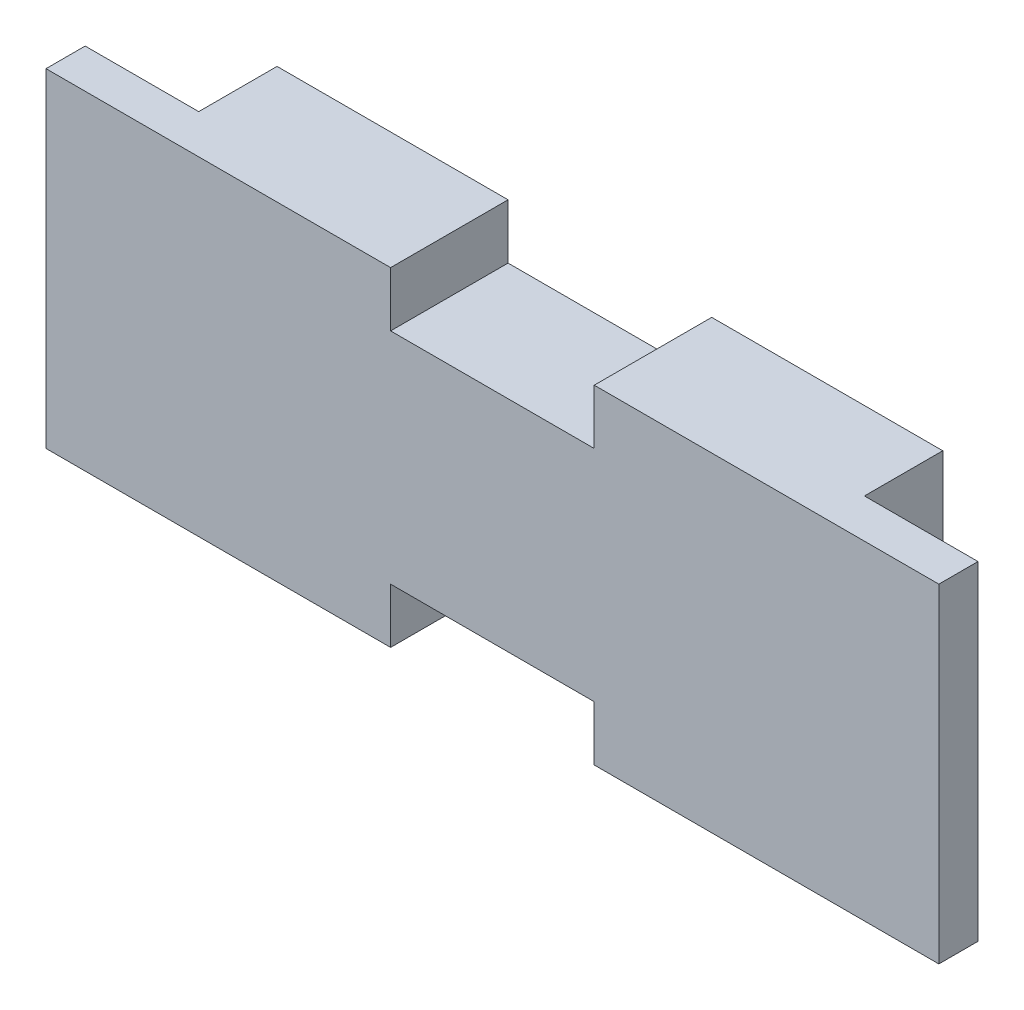
from build123d import *

# Parameters (mm, degrees)
SKETCH1_W           = 57
SKETCH1_H           = 21
BOSS_EXTRUDE1_DEPTH = 2.5
SKETCH2_W           = 42.5
SKETCH2_H           = 21
BOSS_EXTRUDE2_DEPTH = 5
SKETCH3_W           = 13
SKETCH3_H           = 3.5
CUT_EXTRUDE1_DEPTH  = 8.5


with BuildPart() as part:
    # Sketch1 → Boss-Extrude1 (new body)
    with BuildSketch(Plane.XY):
        Rectangle(SKETCH1_W, SKETCH1_H)
    extrude(amount=BOSS_EXTRUDE1_DEPTH)

    # Sketch2 → Boss-Extrude2 (add)
    with BuildSketch(Plane(origin=(0, 0, 0), x_dir=(-1, 0, 0), z_dir=(0, 0, -1))):
        Rectangle(SKETCH2_W, SKETCH2_H)
    extrude(amount=BOSS_EXTRUDE2_DEPTH)

    # Sketch3 → Cut-Extrude1 (cut, through all)
    with BuildSketch(Plane.XY.offset(2.5)):
        with Locations((0, 8.75)):
            Rectangle(SKETCH3_W, SKETCH3_H)
    cut_extrude1 = extrude(amount=-CUT_EXTRUDE1_DEPTH, mode=Mode.SUBTRACT)

    # Mirror1: Cut-Extrude1 across plane
    add(cut_extrude1.mirror(Plane.ZX), mode=Mode.SUBTRACT)


solid = part.part
